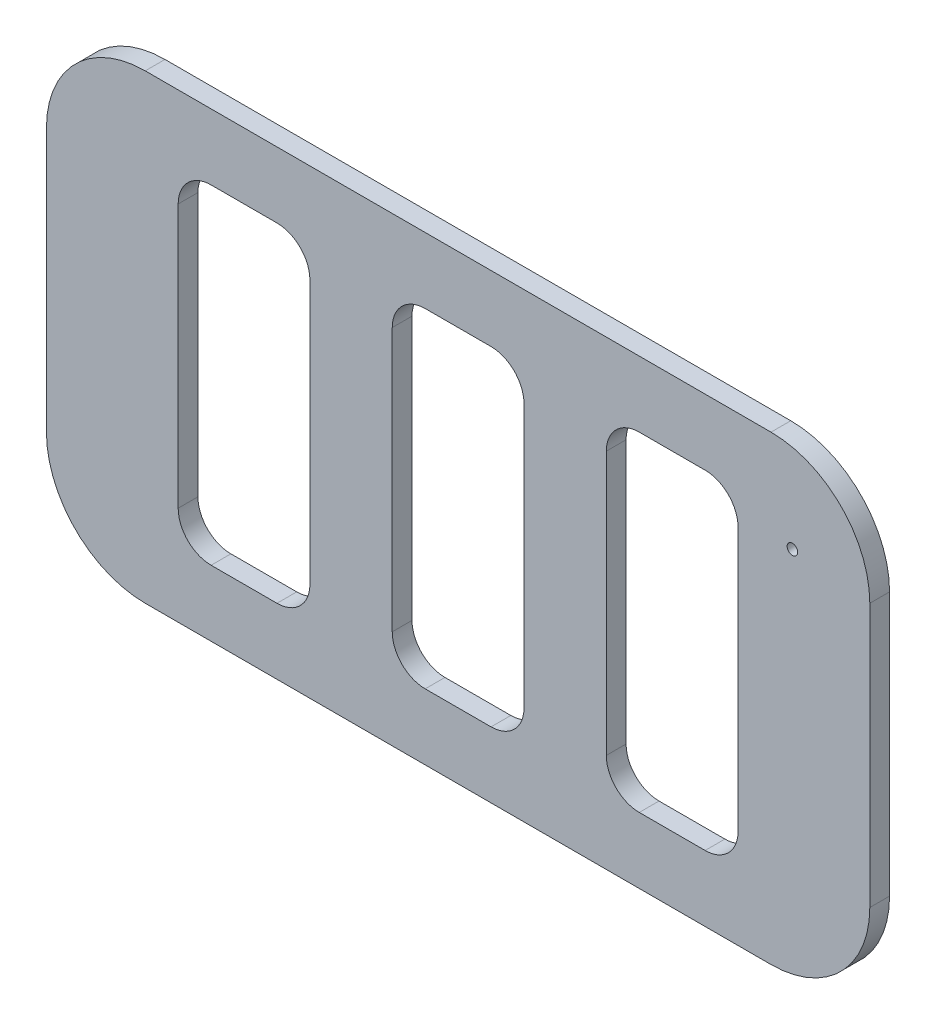
from build123d import *

# Parameters (mm, degrees)
RESSALTO_EXTRUS_O1_DEPTH = 3
ESBO_O2_R                = 0.8
CORTE_EXTRUS_O1_DEPTH    = 4
CORTE_EXTRUS_O2_DEPTH    = 10


with BuildPart() as part:
    # Esboço1 → Ressalto-extrusão1 (new body)
    with BuildSketch(Plane.XY):
        with BuildLine():
            Line((4.586855285, 67.236842105), (99.586855285, 67.236842105))
            ThreePointArc((99.586855285, 67.236842105), (110.193457003, 62.843443823), (114.586855285, 52.236842105))
            Line((114.586855285, 52.236842105), (114.586855285, 12.236842105))
            ThreePointArc((114.586855285, 12.236842105), (110.193457003, 1.630240387), (99.586855285, -2.763157895))
            Line((99.586855285, -2.763157895), (4.586855285, -2.763157895))
            ThreePointArc((4.586855285, -2.763157895), (-6.019746433, 1.630240387), (-10.413144715, 12.236842105))
            Line((-10.413144715, 12.236842105), (-10.413144715, 52.236842105))
            ThreePointArc((-10.413144715, 52.236842105), (-6.019746433, 62.843443823), (4.586855285, 67.236842105))
        make_face()
    extrude(amount=RESSALTO_EXTRUS_O1_DEPTH)

    # Esboço2 → Corte-extrusão1 (cut, through all)
    with BuildSketch(Plane(origin=(0, 0, 0), x_dir=(-1, 0, 0), z_dir=(0, 0, -1))):
        with Locations((-102.836855285, 53.456842105)):
            Circle(ESBO_O2_R)
    extrude(amount=-CORTE_EXTRUS_O1_DEPTH, mode=Mode.SUBTRACT)

    # Esboço3 → Corte-extrusão2 (cut)
    with BuildSketch(Plane(origin=(0, 0, 0), x_dir=(-1, 0, 0), z_dir=(0, 0, -1))):
        with BuildLine():
            Line((-14.586855285, 7.236842105), (-24.586855285, 7.236842105))
            ThreePointArc((-24.586855285, 7.236842105), (-28.122389191, 8.701308199), (-29.586855285, 12.236842105))
            Line((-29.586855285, 12.236842105), (-29.586855285, 52.236842105))
            ThreePointArc((-29.586855285, 52.236842105), (-28.122389191, 55.772376011), (-24.586855285, 57.236842105))
            Line((-24.586855285, 57.236842105), (-14.586855285, 57.236842105))
            ThreePointArc((-14.586855285, 57.236842105), (-11.051321379, 55.772376011), (-9.586855285, 52.236842105))
            Line((-9.586855285, 52.236842105), (-9.586855285, 12.236842105))
            ThreePointArc((-9.586855285, 12.236842105), (-11.051321379, 8.701308199), (-14.586855285, 7.236842105))
        make_face()
        with BuildLine():
            Line((-47.086855285, 7.236842105), (-57.086855285, 7.236842105))
            ThreePointArc((-57.086855285, 7.236842105), (-60.622389191, 8.701308199), (-62.086855285, 12.236842105))
            Line((-62.086855285, 12.236842105), (-62.086855285, 52.236842105))
            ThreePointArc((-62.086855285, 52.236842105), (-60.622389191, 55.772376011), (-57.086855285, 57.236842105))
            Line((-57.086855285, 57.236842105), (-47.086855285, 57.236842105))
            ThreePointArc((-47.086855285, 57.236842105), (-43.551321379, 55.772376011), (-42.086855285, 52.236842105))
            Line((-42.086855285, 52.236842105), (-42.086855285, 12.236842105))
            ThreePointArc((-42.086855285, 12.236842105), (-43.551321379, 8.701308199), (-47.086855285, 7.236842105))
        make_face()
        with BuildLine():
            Line((-79.586855285, 7.236842105), (-89.586855285, 7.236842105))
            ThreePointArc((-89.586855285, 7.236842105), (-93.122389191, 8.701308199), (-94.586855285, 12.236842105))
            Line((-94.586855285, 12.236842105), (-94.586855285, 52.236842105))
            ThreePointArc((-94.586855285, 52.236842105), (-93.122389191, 55.772376011), (-89.586855285, 57.236842105))
            Line((-89.586855285, 57.236842105), (-79.586855285, 57.236842105))
            ThreePointArc((-79.586855285, 57.236842105), (-76.051321379, 55.772376011), (-74.586855285, 52.236842105))
            Line((-74.586855285, 52.236842105), (-74.586855285, 12.236842105))
            ThreePointArc((-74.586855285, 12.236842105), (-76.051321379, 8.701308199), (-79.586855285, 7.236842105))
        make_face()
    extrude(amount=-CORTE_EXTRUS_O2_DEPTH, mode=Mode.SUBTRACT)


solid = part.part
